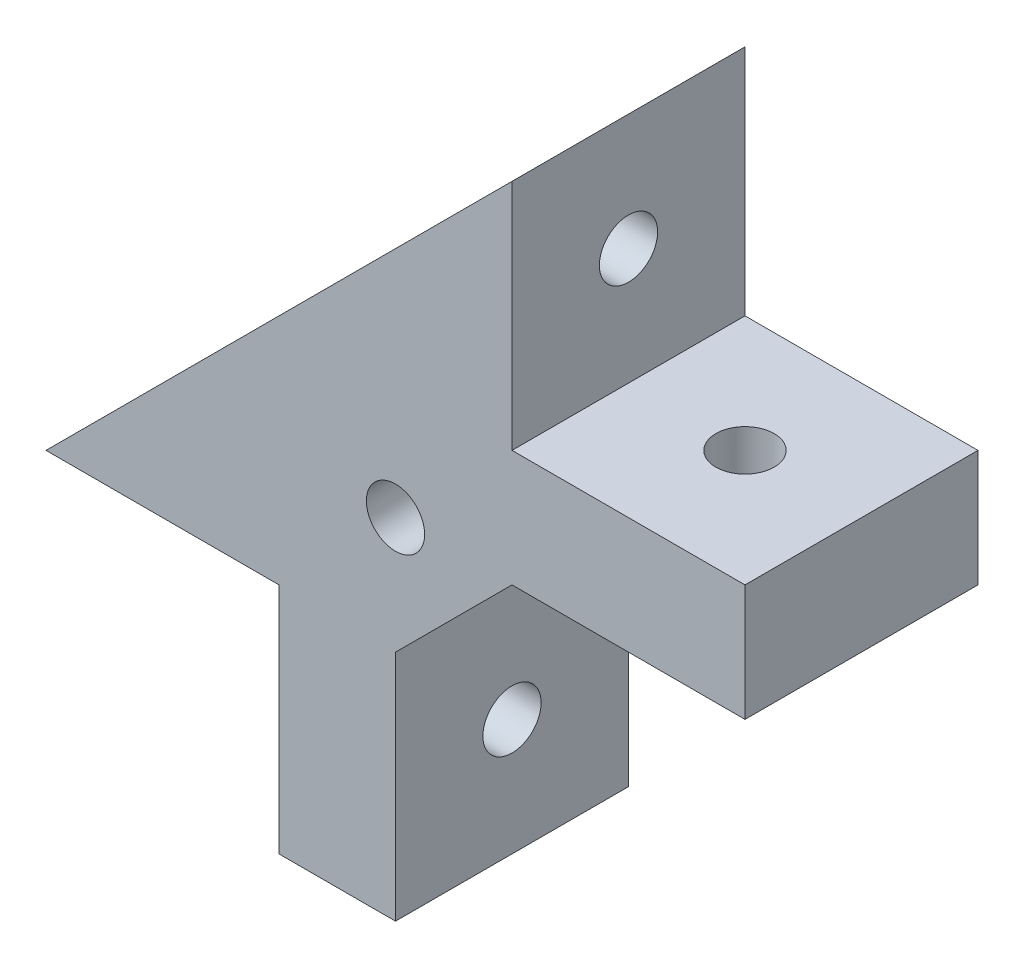
from build123d import *

# Parameters (mm, degrees)
SKETCH1_R          = 1.25
MAIN_DEPTH         = 10
SKETCH2_R          = 1.25
CUT_EXTRUDE1_DEPTH = 21
SKETCH3_R          = 1.25
CUT_EXTRUDE2_DEPTH = 21


with BuildPart() as part:
    # Sketch1 → Main (new body)
    with BuildSketch(Plane.XY):
        Polygon((0, 0), (20, 20), (20, 10), (30, 10), (30, 5), (20, 5), (15, 0), (15, -10), (10, -10), (10, 0), align=None)
        with Locations((15, 5)):
            Circle(SKETCH1_R, mode=Mode.SUBTRACT)
    extrude(amount=MAIN_DEPTH)

    # Sketch2 → Cut-Extrude1 (cut, through all)
    with BuildSketch(Plane(origin=(20, 0, 0), x_dir=(0, 0, -1), z_dir=(1, 0, 0))):
        with Locations((-5, -5)):
            Circle(SKETCH2_R)
        with Locations((-5, 15)):
            Circle(SKETCH2_R)
    extrude(amount=-CUT_EXTRUDE1_DEPTH, mode=Mode.SUBTRACT)

    # Sketch3 → Cut-Extrude2 (cut, through all)
    with BuildSketch(Plane(origin=(0, 0, 0), x_dir=(-1, 0, 0), z_dir=(0, -1, 0))):
        with Locations((-5, -5)):
            Circle(SKETCH3_R)
        with Locations((-25, -5)):
            Circle(SKETCH3_R)
    extrude(amount=-CUT_EXTRUDE2_DEPTH, mode=Mode.SUBTRACT)


solid = part.part
